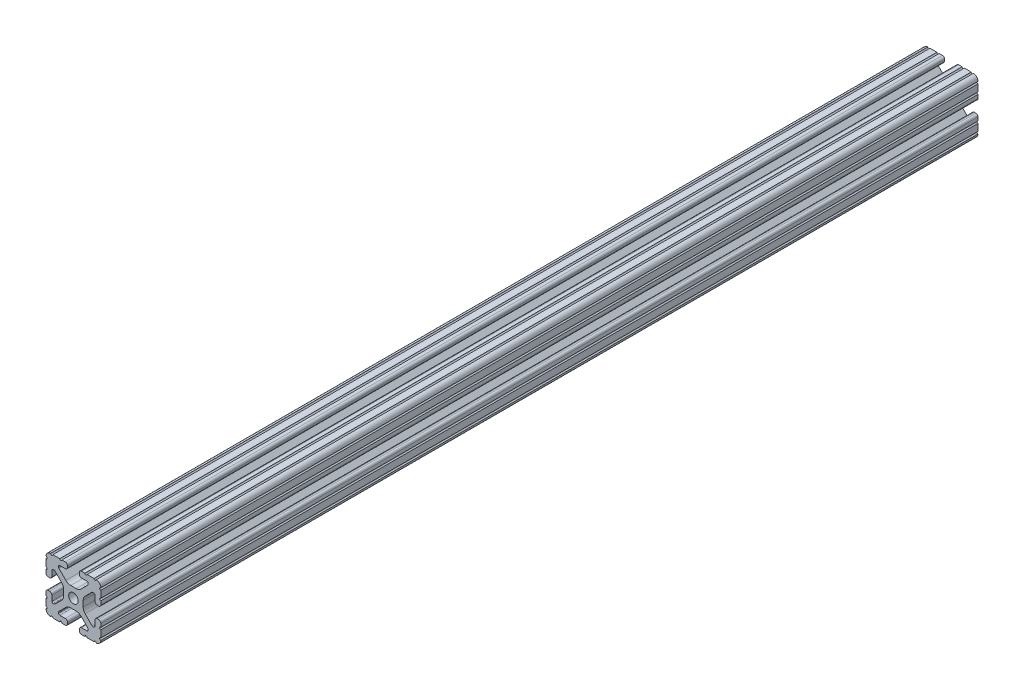
from build123d import *

# Parameters (mm, degrees)
SKETCH1_R      = 3.3274
EXTRUDE1_DEPTH = 609.6


with BuildPart() as part:
    # Sketch1 → Extrude1 (new body)
    with BuildSketch(Plane.XY):
        with BuildLine():
            Line((-10.022898969, 12.91475973), (-5.252158105, 8.144007132))
            ThreePointArc((-5.252158105, 8.144007132), (-3.715177372, 7.117027388), (-1.902183975, 6.7564))
            Line((-1.902183975, 6.7564), (1.902183975, 6.7564))
            ThreePointArc((1.902183975, 6.7564), (3.715177372, 7.117027388), (5.252158105, 8.144007132))
            Line((5.252158105, 8.144007132), (10.022898969, 12.91475973))
            ThreePointArc((10.022898969, 12.91475973), (10.218362387, 13.207291992), (10.287, 13.552357131))
            Line((10.287, 13.552357131), (10.287, 14.0843))
            ThreePointArc((10.287, 14.0843), (10.022898185, 14.721898185), (9.3853, 14.986))
            Line((9.3853, 14.986), (5.617617549, 14.986))
            ThreePointArc((5.617617549, 14.986), (4.519044045, 15.441044045), (4.064, 16.539617549))
            Line((4.064, 16.539617549), (4.064, 17.496382451))
            ThreePointArc((4.064, 17.496382451), (4.519044045, 18.594955955), (5.617617549, 19.05))
            Line((5.617617549, 19.05), (7.974178704, 19.05))
            ThreePointArc((7.974178704, 19.05), (8.736178704, 18.288), (9.498178704, 19.05))
            Line((9.498178704, 19.05), (14.327719207, 19.05))
            ThreePointArc((14.327719207, 19.05), (15.087603123, 18.231251131), (15.847487039, 19.05))
            ThreePointArc((15.847487039, 19.05), (18.120176289, 18.120192083), (19.05, 15.847509295))
            ThreePointArc((19.05, 15.847509295), (18.231250992, 15.08762539), (19.05, 14.327741484))
            Line((19.05, 14.327741484), (19.05, 9.496091471))
            ThreePointArc((19.05, 9.496091471), (18.231250992, 8.736207565), (19.05, 7.97632366))
            Line((19.05, 7.97632366), (19.05, 5.617617549))
            ThreePointArc((19.05, 5.617617549), (18.594955955, 4.519044045), (17.496382451, 4.064))
            Line((17.496382451, 4.064), (16.539617549, 4.064))
            ThreePointArc((16.539617549, 4.064), (15.441044045, 4.519044045), (14.986, 5.617617549))
            Line((14.986, 5.617617549), (14.986, 9.385342516))
            ThreePointArc((14.986, 9.385342516), (14.721898185, 10.022940701), (14.0843, 10.287042516))
            Line((14.0843, 10.287042516), (13.516042086, 10.287042516))
            ThreePointArc((13.516042086, 10.287042516), (13.170975923, 10.218404478), (12.878443117, 10.022939917))
            Line((12.878443117, 10.022939917), (8.14758008, 5.292065243))
            ThreePointArc((8.14758008, 5.292065243), (7.117955879, 3.751120653), (6.7564, 1.933453584))
            Line((6.7564, 1.933453584), (6.7564, -1.933453584))
            ThreePointArc((6.7564, -1.933453584), (7.117955879, -3.751120653), (8.14758008, -5.292065243))
            Line((8.14758008, -5.292065243), (12.878443117, -10.022939917))
            ThreePointArc((12.878443117, -10.022939917), (13.170975923, -10.218404478), (13.516042086, -10.287042516))
            Line((13.516042086, -10.287042516), (14.0843, -10.287042516))
            ThreePointArc((14.0843, -10.287042516), (14.721898185, -10.022940701), (14.986, -9.385342516))
            Line((14.986, -9.385342516), (14.986, -5.617617549))
            ThreePointArc((14.986, -5.617617549), (15.441044045, -4.519044045), (16.539617549, -4.064))
            Line((16.539617549, -4.064), (17.496382451, -4.064))
            ThreePointArc((17.496382451, -4.064), (18.594955955, -4.519044045), (19.05, -5.617617549))
            Line((19.05, -5.617617549), (19.05, -7.976318491))
            ThreePointArc((19.05, -7.976318491), (18.231250992, -8.736202396), (19.05, -9.496086302))
            Line((19.05, -9.496086302), (19.05, -14.32774291))
            ThreePointArc((19.05, -14.32774291), (18.231250992, -15.087626816), (19.05, -15.847510721))
            ThreePointArc((19.05, -15.847510721), (18.120175716, -18.120192644), (15.847486868, -19.05))
            ThreePointArc((15.847486868, -19.05), (15.087602952, -18.231251131), (14.327719036, -19.05))
            Line((14.327719036, -19.05), (9.496062448, -19.05))
            ThreePointArc((9.496062448, -19.05), (8.736178532, -18.231251131), (7.976294616, -19.05))
            Line((7.976294616, -19.05), (5.617617549, -19.05))
            ThreePointArc((5.617617549, -19.05), (4.519044045, -18.594955955), (4.064, -17.496382451))
            Line((4.064, -17.496382451), (4.064, -16.539617549))
            ThreePointArc((4.064, -16.539617549), (4.519044045, -15.441044045), (5.617617549, -14.986))
            Line((5.617617549, -14.986), (9.3853, -14.986))
            ThreePointArc((9.3853, -14.986), (10.022898185, -14.721898185), (10.287, -14.0843))
            Line((10.287, -14.0843), (10.287, -13.552357131))
            ThreePointArc((10.287, -13.552357131), (10.218362387, -13.207291992), (10.022898969, -12.91475973))
            Line((10.022898969, -12.91475973), (5.252158105, -8.144007132))
            ThreePointArc((5.252158105, -8.144007132), (3.715177372, -7.117027388), (1.902183975, -6.7564))
            Line((1.902183975, -6.7564), (-1.902183975, -6.7564))
            ThreePointArc((-1.902183975, -6.7564), (-3.715177372, -7.117027388), (-5.252158105, -8.144007132))
            Line((-5.252158105, -8.144007132), (-10.022898969, -12.91475973))
            ThreePointArc((-10.022898969, -12.91475973), (-10.218362387, -13.207291992), (-10.287, -13.552357131))
            Line((-10.287, -13.552357131), (-10.287, -14.0843))
            ThreePointArc((-10.287, -14.0843), (-10.022898185, -14.721898185), (-9.3853, -14.986))
            Line((-9.3853, -14.986), (-5.617617549, -14.986))
            ThreePointArc((-5.617617549, -14.986), (-4.519044045, -15.441044045), (-4.064, -16.539617549))
            Line((-4.064, -16.539617549), (-4.064, -17.496382451))
            ThreePointArc((-4.064, -17.496382451), (-4.519044045, -18.594955955), (-5.617617549, -19.05))
            Line((-5.617617549, -19.05), (-7.976294616, -19.05))
            ThreePointArc((-7.976294616, -19.05), (-8.736178532, -18.231251131), (-9.496062448, -19.05))
            Line((-9.496062448, -19.05), (-14.327719036, -19.05))
            ThreePointArc((-14.327719036, -19.05), (-15.087602952, -18.231251131), (-15.847486868, -19.05))
            ThreePointArc((-15.847486868, -19.05), (-18.120175716, -18.120192644), (-19.05, -15.847510721))
            ThreePointArc((-19.05, -15.847510721), (-18.231250992, -15.087626816), (-19.05, -14.32774291))
            Line((-19.05, -14.32774291), (-19.05, -9.496086302))
            ThreePointArc((-19.05, -9.496086302), (-18.231250992, -8.736202396), (-19.05, -7.976318491))
            Line((-19.05, -7.976318491), (-19.05, -5.617617549))
            ThreePointArc((-19.05, -5.617617549), (-18.594955955, -4.519044045), (-17.496382451, -4.064))
            Line((-17.496382451, -4.064), (-16.539617549, -4.064))
            ThreePointArc((-16.539617549, -4.064), (-15.441044045, -4.519044045), (-14.986, -5.617617549))
            Line((-14.986, -5.617617549), (-14.986, -9.385342516))
            ThreePointArc((-14.986, -9.385342516), (-14.721898185, -10.022940701), (-14.0843, -10.287042516))
            Line((-14.0843, -10.287042516), (-13.516042086, -10.287042516))
            ThreePointArc((-13.516042086, -10.287042516), (-13.170975923, -10.218404478), (-12.878443117, -10.022939917))
            Line((-12.878443117, -10.022939917), (-8.14758008, -5.292065243))
            ThreePointArc((-8.14758008, -5.292065243), (-7.117955879, -3.751120653), (-6.7564, -1.933453584))
            Line((-6.7564, -1.933453584), (-6.7564, 1.933453584))
            ThreePointArc((-6.7564, 1.933453584), (-7.117955879, 3.751120653), (-8.14758008, 5.292065243))
            Line((-8.14758008, 5.292065243), (-12.878443117, 10.022939917))
            ThreePointArc((-12.878443117, 10.022939917), (-13.170975923, 10.218404478), (-13.516042086, 10.287042516))
            Line((-13.516042086, 10.287042516), (-14.0843, 10.287042516))
            ThreePointArc((-14.0843, 10.287042516), (-14.721898185, 10.022940701), (-14.986, 9.385342516))
            Line((-14.986, 9.385342516), (-14.986, 5.617617549))
            ThreePointArc((-14.986, 5.617617549), (-15.441044045, 4.519044045), (-16.539617549, 4.064))
            Line((-16.539617549, 4.064), (-17.496382451, 4.064))
            ThreePointArc((-17.496382451, 4.064), (-18.594955955, 4.519044045), (-19.05, 5.617617549))
            Line((-19.05, 5.617617549), (-19.05, 7.97632366))
            ThreePointArc((-19.05, 7.97632366), (-18.231250992, 8.736207565), (-19.05, 9.496091471))
            Line((-19.05, 9.496091471), (-19.05, 14.327741484))
            ThreePointArc((-19.05, 14.327741484), (-18.231250992, 15.08762539), (-19.05, 15.847509295))
            ThreePointArc((-19.05, 15.847509295), (-18.120176289, 18.120192083), (-15.847487039, 19.05))
            ThreePointArc((-15.847487039, 19.05), (-15.087603123, 18.231251131), (-14.327719207, 19.05))
            Line((-14.327719207, 19.05), (-9.498178704, 19.05))
            ThreePointArc((-9.498178704, 19.05), (-8.736178704, 18.288), (-7.974178704, 19.05))
            Line((-7.974178704, 19.05), (-5.617617549, 19.05))
            ThreePointArc((-5.617617549, 19.05), (-4.519044045, 18.594955955), (-4.064, 17.496382451))
            Line((-4.064, 17.496382451), (-4.064, 16.539617549))
            ThreePointArc((-4.064, 16.539617549), (-4.519044045, 15.441044045), (-5.617617549, 14.986))
            Line((-5.617617549, 14.986), (-9.3853, 14.986))
            ThreePointArc((-9.3853, 14.986), (-10.022898185, 14.721898185), (-10.287, 14.0843))
            Line((-10.287, 14.0843), (-10.287, 13.552357131))
            ThreePointArc((-10.287, 13.552357131), (-10.218362387, 13.207291992), (-10.022898969, 12.91475973))
        make_face()
        Circle(SKETCH1_R, mode=Mode.SUBTRACT)
    extrude(amount=-EXTRUDE1_DEPTH)


solid = part.part
